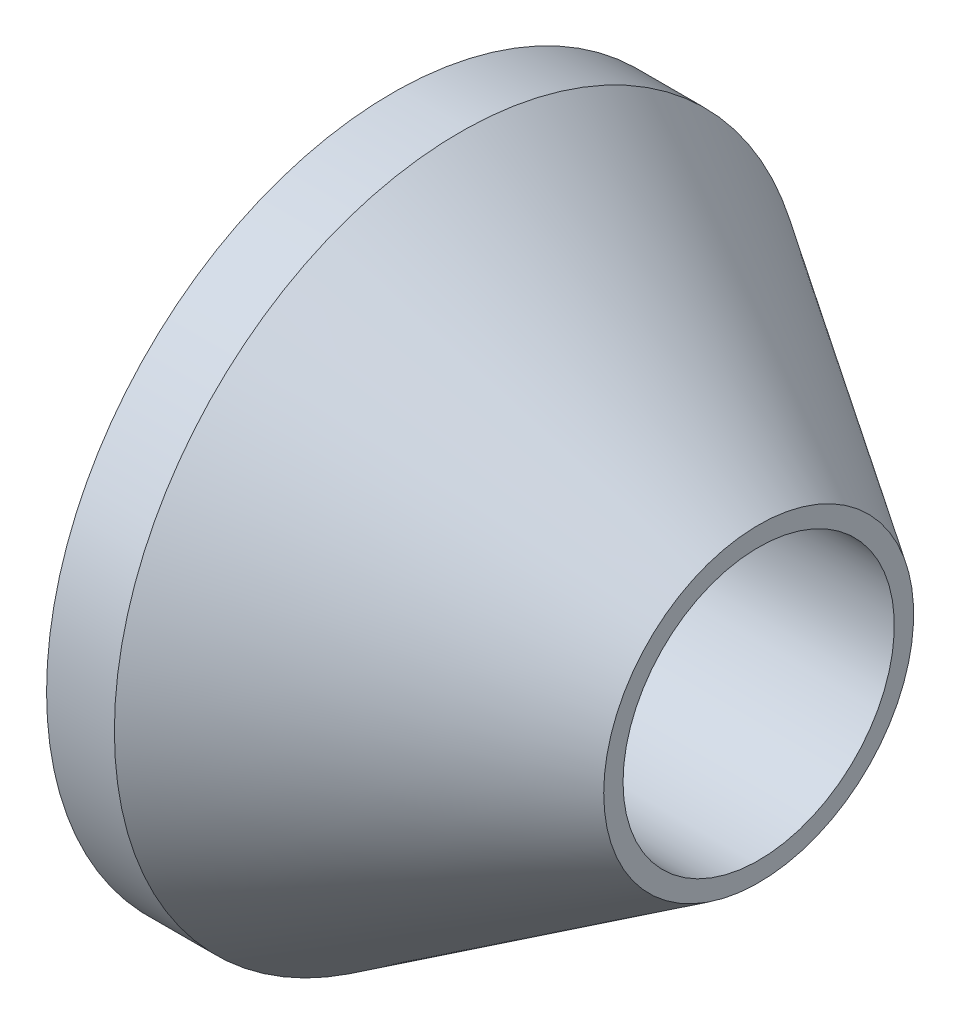
from build123d import *


with BuildPart() as part:
    # Sketch1 → Revolve2 (revolve)
    with BuildSketch(Plane(origin=(0, 0, 0), x_dir=(1, 0, 0), z_dir=(0, 1, 0)), mode=Mode.PRIVATE) as revolve2_sk:
        Polygon((-10.8, 10.2), (-10.8, 0), (-6, 0), (-6, 4), (0, 4), (0, 4.57), (-8.8, 10.2), align=None)
    revolve(revolve2_sk.sketch.rotate(Axis((-6, 0, 0), (1, 0, 0)), 180), axis=Axis((-6, 0, 0), (1, 0, 0)))  # turned: the seam where the file's is


solid = part.part
